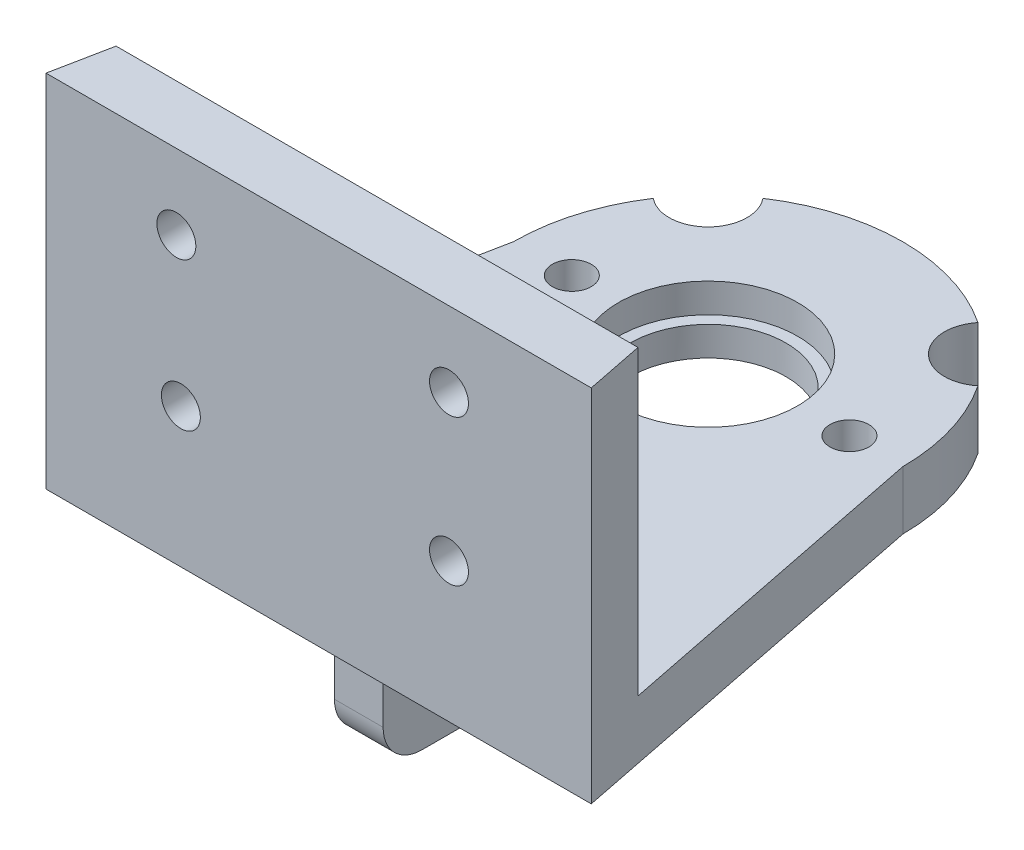
from build123d import *

# Parameters (mm, degrees)
BOSS_EXTRUDE1_DEPTH = 3
SKETCH2_R           = 4
CUT_EXTRUDE1_DEPTH  = 13
BOSS_EXTRUDE2_DEPTH = 15.5
SKETCH6_R           = 4.6
CUT_EXTRUDE4_DEPTH  = 1.5
SKETCH7_R           = 2
CUT_EXTRUDE5_DEPTH  = 10
SKETCH8_R           = 1
CUT_EXTRUDE6_DEPTH  = 10
SKETCH4_R           = 1
CUT_EXTRUDE9_DEPTH  = 3
SKETCH11_R          = 1
CUT_EXTRUDE11_DEPTH = 3
SKETCH12_W          = 2.5
SKETCH12_H          = 7
BOSS_EXTRUDE3_DEPTH = 6
SKETCH13_R          = 1
CUT_EXTRUDE12_DEPTH = 6
FILLET1_R           = 2


with BuildPart() as part:
    # Sketch1 → Boss-Extrude1 (new body)
    with BuildSketch(Plane(origin=(0, 0, 0), x_dir=(1, 0, 0), z_dir=(0, 1, 0))):
        with BuildLine():
            Line((-10, 0), (-14, -20))
            Line((-14, -20), (14, -20))
            Line((14, -20), (10, 0))
            ThreePointArc((10, 0), (0, 10), (-10, 0))
        make_face()
    extrude(amount=BOSS_EXTRUDE1_DEPTH)

    # Sketch2 → Cut-Extrude1 (cut)
    with BuildSketch(Plane(origin=(0, 3, 0), x_dir=(1, 0, 0), z_dir=(0, 1, 0))):
        Circle(SKETCH2_R)
    extrude(amount=-CUT_EXTRUDE1_DEPTH, mode=Mode.SUBTRACT)

    # Sketch5 → Boss-Extrude2 (add)
    with BuildSketch(Plane(origin=(0, 3, 0), x_dir=(1, 0, 0), z_dir=(0, 1, 0))):
        Polygon((-13.4, -17), (13.4, -17), (14, -20), (-14, -20), align=None)
    extrude(amount=BOSS_EXTRUDE2_DEPTH)

    # Sketch6 → Cut-Extrude4 (cut)
    with BuildSketch(Plane(origin=(0, 3, 0), x_dir=(1, 0, 0), z_dir=(0, 1, 0))):
        Circle(SKETCH6_R)
    extrude(amount=-CUT_EXTRUDE4_DEPTH, mode=Mode.SUBTRACT)

    # Sketch7 → Cut-Extrude5 (cut)
    with BuildSketch(Plane(origin=(0, 3, 0), x_dir=(1, 0, 0), z_dir=(0, 1, 0))):
        with Locations((-7.071067812, 7.071067812)):
            Circle(SKETCH7_R)
        with Locations((7.071067812, 7.071067812)):
            Circle(SKETCH7_R)
    extrude(amount=-CUT_EXTRUDE5_DEPTH, mode=Mode.SUBTRACT)

    # Sketch8 → Cut-Extrude6 (cut)
    with BuildSketch(Plane(origin=(0, 0, 17), x_dir=(-1, 0, 0), z_dir=(0, 0, -1))):
        with Locations((-6.69393863, 7.151837118)):
            Circle(SKETCH8_R)
        with Locations((-6.69393863, 14.651837118)):
            Circle(SKETCH8_R)
        with Locations((7.30606137, 14.651837118)):
            Circle(SKETCH8_R)
        with Locations((7.073668949, 7.151837118)):
            Circle(SKETCH8_R)
    extrude(amount=-CUT_EXTRUDE6_DEPTH, mode=Mode.SUBTRACT)

    # Sketch4 → Cut-Extrude9 (cut)
    with BuildSketch(Plane(origin=(0, 3, 0), x_dir=(1, 0, 0), z_dir=(0, 1, 0))):
        with Locations((-7, 0)):
            Circle(SKETCH4_R)
    extrude(amount=-CUT_EXTRUDE9_DEPTH, mode=Mode.SUBTRACT)

    # Sketch11 → Cut-Extrude11 (cut)
    with BuildSketch(Plane(origin=(0, 3, 0), x_dir=(1, 0, 0), z_dir=(0, 1, 0))):
        with Locations((0, -7.597940957)):
            Circle(SKETCH11_R)
        with Locations((7.256224789, 0)):
            Circle(SKETCH11_R)
    extrude(amount=-CUT_EXTRUDE11_DEPTH, mode=Mode.SUBTRACT)

    # Sketch12 → Boss-Extrude3 (add)
    with BuildSketch(Plane.XZ):
        with Locations((0, 14.439281905)):
            Rectangle(SKETCH12_W, SKETCH12_H)
    extrude(amount=BOSS_EXTRUDE3_DEPTH)

    # Sketch13 → Cut-Extrude12 (cut)
    with BuildSketch(Plane.ZY.offset(1.25)):
        with Locations((14.409447897, -3)):
            Circle(SKETCH13_R)
    extrude(amount=-CUT_EXTRUDE12_DEPTH, mode=Mode.SUBTRACT)

    # Fillet1
    fillet1_edges = [part.edges().sort_by_distance(p)[0] for p in [
        (0, -6, 17.939281905),
        (0, 0, 10.939281905),
        (0, 0, 17.939281905),
        (0, -6, 10.939281905),
    ]]
    fillet(fillet1_edges, radius=FILLET1_R)


solid = part.part
